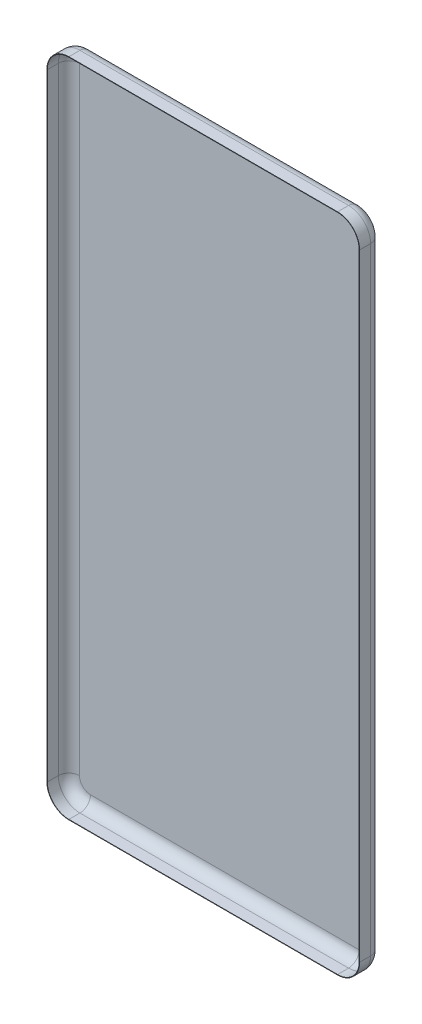
from build123d import *

# Parameters (mm, degrees)
BOSS_EXTRUDE1_DEPTH = 200
FILLET1_R           = 50
SKETCH2_W           = 178.413306637
SKETCH2_H           = 3000
CUT_EXTRUDE1_DEPTH  = 1420
SHELL1_T            = -2


with BuildPart() as part:
    # Sketch1 → Boss-Extrude1 (new body)
    with BuildSketch(Plane.XY):
        with BuildLine():
            Line((-1300, 0), (-81, 0))
            ThreePointArc((-81, 0), (-10.289321881, -29.289321881), (19, -100))
            Line((19, -100), (19, -2899))
            ThreePointArc((19, -2899), (-10.289321881, -2969.710678119), (-81, -2999))
            Line((-81, -2999), (-1300, -2999))
            ThreePointArc((-1300, -2999), (-1370.710678119, -2969.710678119), (-1400, -2899))
            Line((-1400, -2899), (-1400, -100))
            ThreePointArc((-1400, -100), (-1370.710678119, -29.289321881), (-1300, 0))
        make_face()
    extrude(amount=BOSS_EXTRUDE1_DEPTH)

    # Fillet1
    fillet1_edges = [part.edges().sort_by_distance(p)[0] for p in [
        (19, -1499.5, 0),
        (-10.289321881, -2969.710678119, 0),
        (-690.5, -2999, 0),
        (-1370.710678119, -2969.710678119, 0),
        (-10.289321881, -2969.710678119, 200),
        (19, -1499.5, 200),
        (-10.289321881, -29.289321881, 200),
        (-690.5, 0, 200),
        (-1370.710678119, -29.289321881, 200),
        (-1400, -1499.5, 200),
        (-1370.710678119, -2969.710678119, 200),
        (-1400, -1499.5, 0),
        (-690.5, -2999, 200),
        (-1370.710678119, -29.289321881, 0),
        (-690.5, 0, 0),
        (-10.289321881, -29.289321881, 0),
    ]]
    fillet(fillet1_edges, radius=FILLET1_R)

    # Sketch2 → Cut-Extrude1 (cut, through all)
    with BuildSketch(Plane(origin=(19, 0, 0), x_dir=(0, 0, -1), z_dir=(1, 0, 0))):
        with Locations((-189.206653319, -1500)):
            Rectangle(SKETCH2_W, SKETCH2_H)
    extrude(amount=-CUT_EXTRUDE1_DEPTH, mode=Mode.SUBTRACT)

    # Shell1
    shell1_openings = [part.faces().sort_by_distance(p)[0] for p in [
        (-690.5, -1499.5, 100),
    ]]
    offset(amount=SHELL1_T, openings=shell1_openings, kind=Kind.INTERSECTION)


solid = part.part
